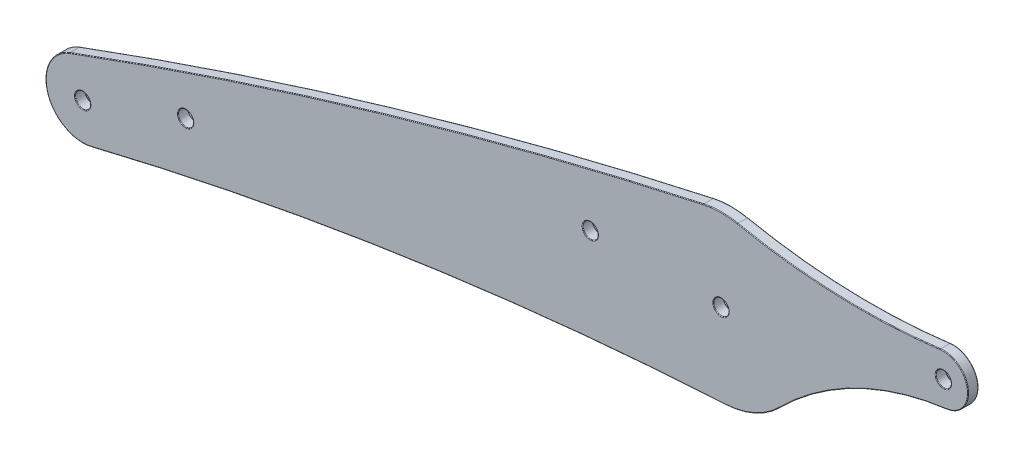
from build123d import *

# Parameters (mm, degrees)
BOSS_EXTRUDE1_DEPTH    = 2.5
M3_5_CLEARANCE_HOLE1_D = 3.7
FILLET1_R              = 0.15


with BuildPart() as part:
    # Sketch1 → Boss-Extrude1 (new body)
    with BuildSketch(Plane.XY):
        with BuildLine():
            ThreePointArc((-210.687563405, 176.430415278), (-134.535098185, 201.674243308), (-56.807931252, 221.547248443))
            ThreePointArc((-56.807931252, 221.547248443), (-52.672754251, 222.009046999), (-48.531514092, 221.605219452))
            ThreePointArc((-48.531514092, 221.605219452), (-23.990742385, 218.672526348), (0.698476803, 219.809461122))
            ThreePointArc((0.698476803, 219.809461122), (7.417769775, 214.628511061), (2.237646451, 207.908580709))
            ThreePointArc((2.237646451, 207.908580709), (-19.725912052, 201.273717505), (-38.364370977, 187.893614338))
            ThreePointArc((-38.364370977, 187.893614338), (-44.354789248, 183.757900443), (-51.428556806, 182.040037523))
            ThreePointArc((-51.428556806, 182.040037523), (-128.953188889, 174.176537638), (-205.431945408, 159.246600894))
            ThreePointArc((-205.431945408, 159.246600894), (-216.165883539, 165.359272847), (-210.687563405, 176.430415278))
        make_face()
    extrude(amount=-BOSS_EXTRUDE1_DEPTH)

    # M3.5 Clearance Hole1 (through all)
    with Locations(Plane.XY):
        with Locations((-207.559420674, 167.991533655), (-182.559420674, 176.69777236), (-84.282670476, 202.216511621), (-52.532670476, 202.009537592), (1.467329524, 213.858926231)):
            Hole(M3_5_CLEARANCE_HOLE1_D / 2)

    # Fillet1
    fillet1_edges = [part.edges().sort_by_distance(p)[0] for p in [
        (-19.725912052, 201.273717505, 0),
        (-44.354789248, 183.757900443, 0),
        (-128.953188889, 174.176537638, 0),
        (-216.165883539, 165.359272847, 0),
        (-44.354789248, 183.757900443, -2.5),
        (-19.725912052, 201.273717505, -2.5),
        (7.417769775, 214.628511061, -2.5),
        (-23.990742385, 218.672526348, -2.5),
        (3.317329524, 213.858926231, 0),
        (3.317329524, 213.858926231, -2.5),
        (-52.672754251, 222.009046999, -2.5),
        (-134.535098185, 201.674243308, -2.5),
        (-50.682670476, 202.009537592, 0),
        (-50.682670476, 202.009537592, -2.5),
        (-82.432670476, 202.216511621, 0),
        (-82.432670476, 202.216511621, -2.5),
        (-180.709420674, 176.69777236, 0),
        (-180.709420674, 176.69777236, -2.5),
        (-205.709420674, 167.991533655, 0),
        (-205.709420674, 167.991533655, -2.5),
        (-216.165883539, 165.359272847, -2.5),
        (-134.535098185, 201.674243308, 0),
        (-128.953188889, 174.176537638, -2.5),
        (-52.672754251, 222.009046999, 0),
        (-23.990742385, 218.672526348, 0),
        (7.417769775, 214.628511061, 0),
    ]]
    fillet(fillet1_edges, radius=FILLET1_R)


solid = part.part
